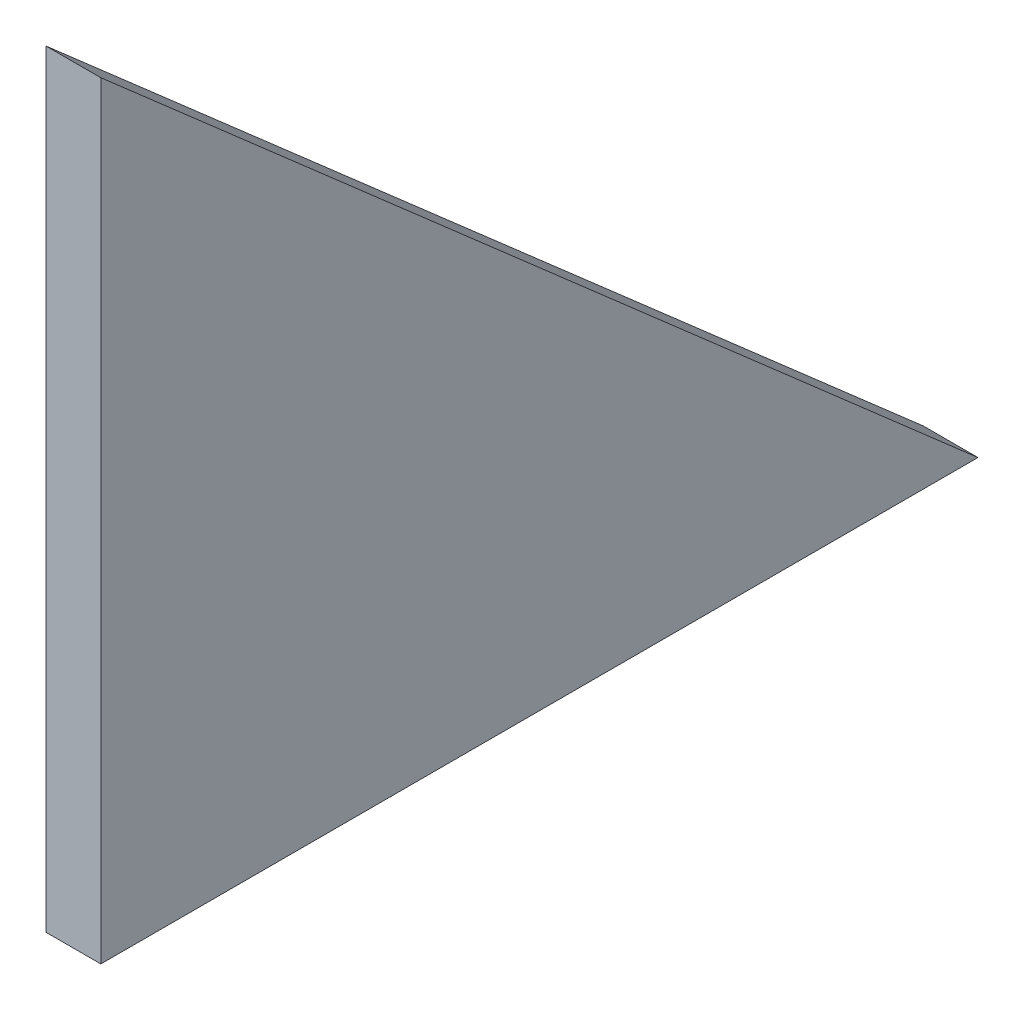
from build123d import *

# Parameters (mm, degrees)
BOSS_EXTRUDE1_DEPTH = 5


with BuildPart() as part:
    # Sketch1 → Boss-Extrude1 (new body)
    with BuildSketch(Plane(origin=(0, 0, 0), x_dir=(0, 0, -1), z_dir=(1, 0, 0))):
        Polygon((0, 0), (0, 70), (80, 0), align=None)
    extrude(amount=BOSS_EXTRUDE1_DEPTH)


solid = part.part
